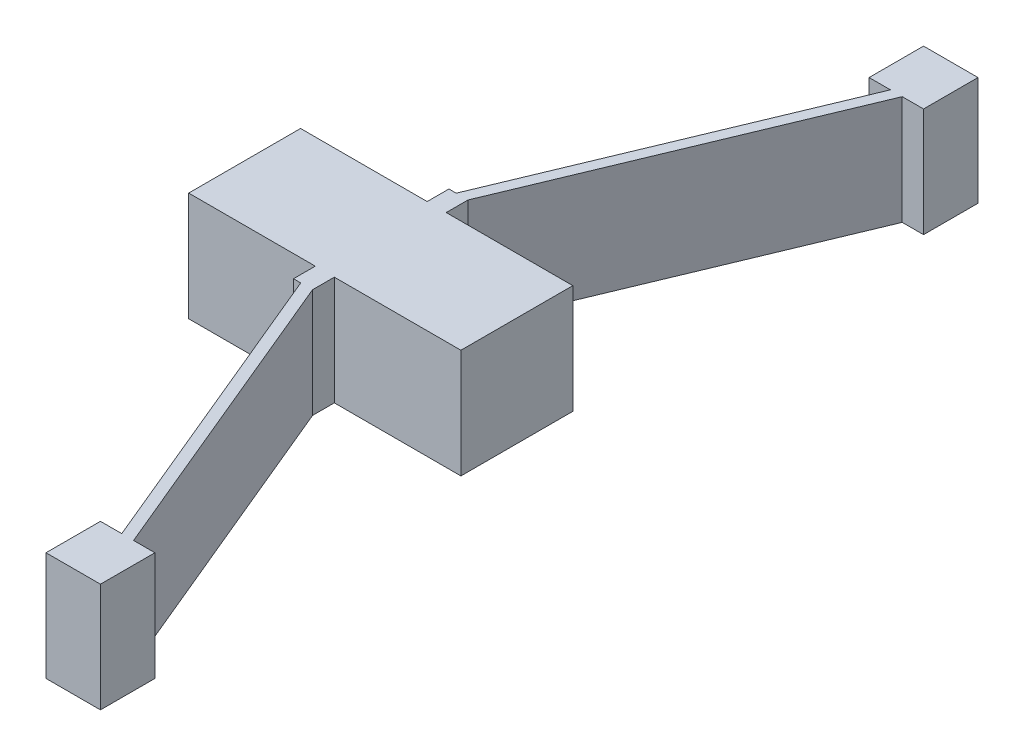
from build123d import *

# Parameters (mm, degrees)
BOSS_EXTRUDE1_DEPTH = 0.04


with BuildPart() as part:
    # Sketch1 → Boss-Extrude1 (new body)
    with BuildSketch(Plane(origin=(0, 0, 0), x_dir=(1, 0, 0), z_dir=(0, 1, 0))):
        Polygon((0.0465, 0.02055), (0, 0.02055), (0, -0.02055), (0.0465, -0.02055), (0.0535, -0.02055), (0.1, -0.02055), (0.1, 0.02055), (0.0535, 0.02055), align=None)
        Polygon((0.0465, 0.02855), (0.0465, 0.02055), (0.0535, 0.02055), (0.0535, 0.02855), (0.049167292, 0.02855), align=None)
        Polygon((0.0535, -0.02055), (0.0465, -0.02055), (0.0465, -0.02855), (0.049167292, -0.02855), (0.0535, -0.02855), align=None)
        Polygon((0.049167292, 0.02855), (0.0535, 0.02855), (0.100384029, 0.141181646), (0.096051322, 0.141181646), align=None)
        Polygon((0.096051322, 0.141181646), (0.100384029, 0.141181646), (0.108217676, 0.141181646), (0.108217676, 0.161181646), (0.088217676, 0.161181646), (0.088217676, 0.141181646), align=None)
        Polygon((0.100384029, -0.141181646), (0.0535, -0.02855), (0.049167292, -0.02855), (0.096051322, -0.141181646), align=None)
        Polygon((0.108217676, -0.141181646), (0.100384029, -0.141181646), (0.096051322, -0.141181646), (0.088217676, -0.141181646), (0.088217676, -0.161181646), (0.108217676, -0.161181646), align=None)
    extrude(amount=BOSS_EXTRUDE1_DEPTH)


solid = part.part
